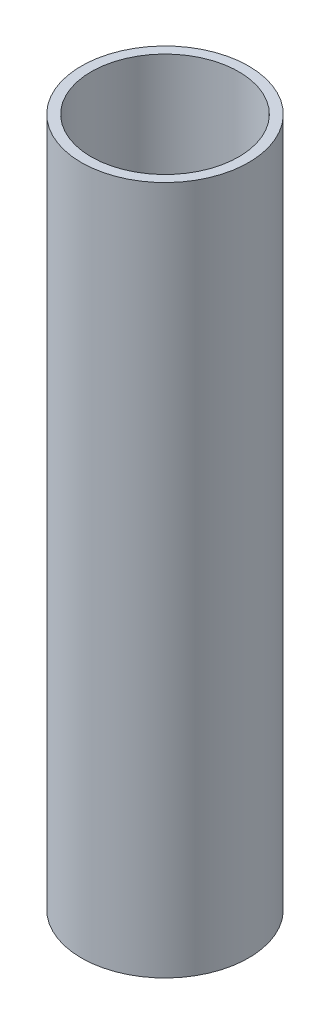
from build123d import *

# Parameters (mm, degrees)
SKETCH1_R           = 17
SKETCH1_R_2         = 15
BOSS_EXTRUDE1_DEPTH = 140


with BuildPart() as part:
    # Sketch1 → Boss-Extrude1 (new body)
    with BuildSketch(Plane(origin=(0, 0, 0), x_dir=(1, 0, 0), z_dir=(0, 1, 0))):
        Circle(SKETCH1_R)
        Circle(SKETCH1_R_2, mode=Mode.SUBTRACT)
    extrude(amount=BOSS_EXTRUDE1_DEPTH)


solid = part.part
